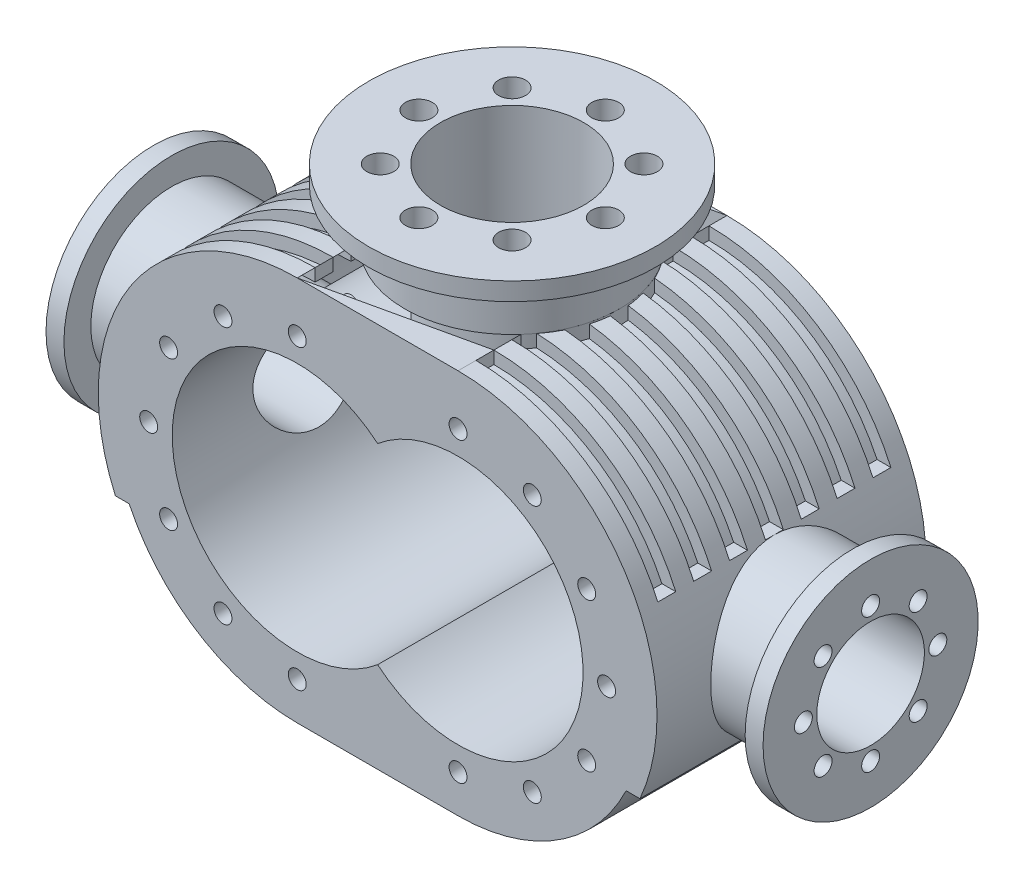
from build123d import *

# Parameters (mm, degrees)
Y_KSEKLIK_EKSTR_ZYON1_DEPTH = 75
Y_KSEKLIK_EKSTR_ZYON2_DEPTH = 75
IZIM1_10_W                  = 89.69
IZIM1_10_H                  = 7
Y_KSEKLIK_EKSTR_ZYON3_DEPTH = 75
IZIM3_W                     = 89.69
IZIM3_H                     = 7
KES_EKSTR_ZYON4_DEPTH       = 5.991017223
KES_EKSTR_ZYON4_DEPTH_BACK  = 155.991017223
Y_KSEKLIK_EKSTR_ZYON4_START = -8.110127
IZIM4_R                     = 60
Y_KSEKLIK_EKSTR_ZYON4_DEPTH = 8.110127
IZIM5_R                     = 40
KES_EKSTR_ZYON5_DEPTH       = 112
IZIM6_R                     = 30
KES_EKSTR_ZYON6_DEPTH       = 401
IZIM7_R                     = 5
KES_EKSTR_ZYON7_DEPTH       = 30
IZIM8_R                     = 5
KES_EKSTR_ZYON8_DEPTH       = 30
IZIM9_R                     = 7.5
KES_EKSTR_ZYON9_DEPTH       = 40
Y_KSEKLIK_EKSTR_ZYON5_DEPTH = 10
L_O_ALTMA2_COUNT            = 10
L_O_ALTMA2_PITCH            = 20
AYNALAMA3_COPY_1_DEPTH      = 10
AYNALAMA3_COPY_2_DEPTH      = 10
AYNALAMA3_COPY_3_DEPTH      = 10
AYNALAMA3_COPY_4_DEPTH      = 10
AYNALAMA3_COPY_5_DEPTH      = 10
AYNALAMA3_COPY_6_DEPTH      = 10
AYNALAMA3_COPY_7_DEPTH      = 10


with BuildPart() as part:
    # Çizim1 → Yükseklik-Ekstrüzyon1 (new body, symmetric)
    with BuildSketch(Plane.XY):
        with BuildLine():
            Line((-44.845, 111), (-44.845, 104))
            ThreePointArc((-44.845, 104), (-148.845, 0), (-44.845, -104))
            Line((-44.845, -104), (-44.845, -111))
            ThreePointArc((-44.845, -111), (-155.845, 0), (-44.845, 111))
        make_face()
    extrude(amount=Y_KSEKLIK_EKSTR_ZYON1_DEPTH, both=True)

    # Çizim1<5> → Döndür2 (revolve)
    with BuildSketch(Plane.XY):
        with BuildLine():
            Line((-200, 0), (-155.845, 0))
            ThreePointArc((-155.845, 0), (-153.436164451, 22.999108745), (-146.314207152, 45))
            Line((-146.314207152, 45), (-190, 45))
            Line((-190, 45), (-190, 60))
            Line((-190, 60), (-200, 60))
            Line((-200, 60), (-200, 0))
        make_face()
    revolve(axis=Axis((0, 0, 0), (1, 0, 0)))



with BuildPart() as body_2:
    # Çizim1<6> → Döndür3 (revolve)
    with BuildSketch(Plane.XY):
        with BuildLine():
            Line((200, 0), (200, 60))
            Line((200, 60), (190, 60))
            Line((190, 60), (190, 45))
            Line((190, 45), (146.314207152, 45))
            ThreePointArc((146.314207152, 45), (153.436164451, 22.999108745), (155.845, 0))
            Line((155.845, 0), (200, 0))
        make_face()
    revolve(axis=Axis((0, 0, 0), (1, 0, 0)))


with BuildPart() as body_3:
    # Çizim1<7> → Döndür4 (revolve)
    with BuildSketch(Plane.XY):
        with BuildLine():
            Line((-44.845, 111), (0, 111))
            Line((0, 111), (0, 151.000138756))
            Line((0, 151.000138756), (-79.991017223, 151.000138756))
            Line((-79.991017223, 151.000138756), (-79.991017223, 141.000138756))
            Line((-79.991017223, 141.000138756), (-59.991017223, 141.000138756))
            Line((-59.991017223, 141.000138756), (-59.991017223, 109.961803197))
            ThreePointArc((-59.991017223, 109.961803197), (-52.435778786, 110.740146638), (-44.845, 111))
        make_face()
    revolve(axis=Axis((0, 159.5984811, 0), (0, -1, 0)))


with BuildPart() as part_1:
    add(part.part)

    add(body_2.part)  # Yükseklik-Ekstrüzyon2 merges body 2

    add(body_3.part)  # Yükseklik-Ekstrüzyon2 merges body 3
    # Çizim1<9> → Yükseklik-Ekstrüzyon2 (add, symmetric)
    with BuildSketch(Plane.XY):
        with BuildLine():
            Line((-44.845, -104), (44.845, -104))
            ThreePointArc((44.845, -104), (148.845, 0), (44.845, 104))
            Line((44.845, 104), (44.845, 111))
            Line((44.845, 111), (-44.845, 111))
            Line((-44.845, 111), (-44.845, 104))
            ThreePointArc((-44.845, 104), (-148.845, 0), (-44.845, -104))
        make_face()
        with BuildLine():
            ThreePointArc((0, -53.422733691), (114.595, 0), (0, 53.422733691))
            ThreePointArc((0, 53.422733691), (-114.595, 0), (0, -53.422733691))
        make_face(mode=Mode.SUBTRACT)
    extrude(amount=Y_KSEKLIK_EKSTR_ZYON2_DEPTH, both=True)

    # Çizim1<10> → Yükseklik-Ekstrüzyon3 (add, symmetric)
    with BuildSketch(Plane.XY):
        with BuildLine():
            ThreePointArc((44.845, -104), (148.845, 0), (44.845, 104))
            Line((44.845, 104), (44.845, 111))
            ThreePointArc((44.845, 111), (155.845, 0), (44.845, -111))
            Line((44.845, -111), (44.845, -104))
        make_face()
        with Locations((0, -107.5)):
            Rectangle(IZIM1_10_W, IZIM1_10_H)
    extrude(amount=Y_KSEKLIK_EKSTR_ZYON3_DEPTH, both=True)

    # Çizim3 → Kes-Ekstrüzyon4 (cut, two sides)
    with BuildSketch(Plane.XY.offset(75)) as kes_ekstr_zyon4_sk:
        with BuildLine():
            ThreePointArc((-44.845, 111), (-105.367723005, 93.048374516), (-146.314207152, 45))
            Line((-146.314207152, 45), (-138.605332764, 45))
            ThreePointArc((-138.605332764, 45), (-100.234529697, 88.022724339), (-44.845, 104))
            Line((-44.845, 104), (-44.845, 111))
        make_face()
        with BuildLine():
            Line((-138.605332764, -45), (-146.314207152, -45))
            ThreePointArc((-146.314207152, -45), (-105.367723005, -93.048374516), (-44.845, -111))
            Line((-44.845, -111), (-44.845, -104))
            ThreePointArc((-44.845, -104), (-100.234529697, -88.022724339), (-138.605332764, -45))
        make_face()
        with Locations((0, -107.5)):
            Rectangle(IZIM3_W, IZIM3_H)
        with BuildLine():
            Line((44.845, -104), (44.845, -111))
            ThreePointArc((44.845, -111), (105.367723005, -93.048374516), (146.314207152, -45))
            Line((146.314207152, -45), (138.605332764, -45))
            ThreePointArc((138.605332764, -45), (100.234529697, -88.022724339), (44.845, -104))
        make_face()
        with BuildLine():
            Line((138.605332764, 45), (146.314207152, 45))
            ThreePointArc((146.314207152, 45), (105.367723005, 93.048374516), (44.845, 111))
            Line((44.845, 111), (44.845, 104))
            ThreePointArc((44.845, 104), (100.234529697, 88.022724339), (138.605332764, 45))
        make_face()
    extrude(amount=KES_EKSTR_ZYON4_DEPTH, mode=Mode.SUBTRACT)
    extrude(kes_ekstr_zyon4_sk.sketch, amount=-KES_EKSTR_ZYON4_DEPTH_BACK, mode=Mode.SUBTRACT)

    # Çizim4 → Yükseklik-Ekstrüzyon4 (add)
    with BuildSketch(Plane(origin=(0, 111, 0), x_dir=(1, 0, 0), z_dir=(0, 1, 0)).offset(Y_KSEKLIK_EKSTR_ZYON4_START)):
        Circle(IZIM4_R)
    extrude(amount=Y_KSEKLIK_EKSTR_ZYON4_DEPTH)

    # Çizim5 → Kes-Ekstrüzyon5 (cut)
    with BuildSketch(Plane(origin=(0, 151.000138756, 0), x_dir=(1, 0, 0), z_dir=(0, 1, 0))):
        Circle(IZIM5_R)
    extrude(amount=-KES_EKSTR_ZYON5_DEPTH, mode=Mode.SUBTRACT)

    # Çizim6 → Kes-Ekstrüzyon6 (cut, through all)
    with BuildSketch(Plane.ZY.offset(200)):
        Circle(IZIM6_R)
    extrude(amount=-KES_EKSTR_ZYON6_DEPTH, mode=Mode.SUBTRACT)

    # Çizim7 → Kes-Ekstrüzyon7 (cut)
    with BuildSketch(Plane(origin=(0, 0, -75), x_dir=(-1, 0, 0), z_dir=(0, 0, -1))):
        with Locations((-127.72, 0)):
            Circle(IZIM7_R)
        with Locations((-116.616855339, -41.4375)):
            Circle(IZIM7_R)
        with Locations((-86.2825, -71.771855339)):
            Circle(IZIM7_R)
        with Locations((-44.845, -82.875)):
            Circle(IZIM7_R)
        with Locations((-116.616855339, 41.4375)):
            Circle(IZIM7_R)
        with Locations((-86.2825, 71.771855339)):
            Circle(IZIM7_R)
        with Locations((-44.845, 82.875)):
            Circle(IZIM7_R)
        with Locations((44.845, -82.875)):
            Circle(IZIM7_R)
        with Locations((86.2825, -71.771855339)):
            Circle(IZIM7_R)
        with Locations((116.616855339, -41.4375)):
            Circle(IZIM7_R)
        with Locations((127.72, 0)):
            Circle(IZIM7_R)
        with Locations((116.616855339, 41.4375)):
            Circle(IZIM7_R)
        with Locations((86.2825, 71.771855339)):
            Circle(IZIM7_R)
        with Locations((44.845, 82.875)):
            Circle(IZIM7_R)
    kes_ekstr_zyon7 = extrude(amount=-KES_EKSTR_ZYON7_DEPTH, mode=Mode.SUBTRACT)

    # Aynalama1: Kes-Ekstrüzyon7 across plane
    add(kes_ekstr_zyon7.mirror(Plane.XY), mode=Mode.SUBTRACT)

    # Çizim8 → Kes-Ekstrüzyon8 (cut)
    with BuildSketch(Plane.ZY.offset(200)):
        with Locations((0, 37.5)):
            Circle(IZIM8_R)
        with Locations((26.516504294, 26.516504294)):
            Circle(IZIM8_R)
        with Locations((37.5, 0)):
            Circle(IZIM8_R)
        with Locations((26.516504294, -26.516504294)):
            Circle(IZIM8_R)
        with Locations((0, -37.5)):
            Circle(IZIM8_R)
        with Locations((-26.516504294, -26.516504294)):
            Circle(IZIM8_R)
        with Locations((-37.5, 0)):
            Circle(IZIM8_R)
        with Locations((-26.516504294, 26.516504294)):
            Circle(IZIM8_R)
    kes_ekstr_zyon8 = extrude(amount=-KES_EKSTR_ZYON8_DEPTH, mode=Mode.SUBTRACT)

    # Aynalama2: Kes-Ekstrüzyon8 across plane
    add(kes_ekstr_zyon8.mirror(Plane(origin=(0, 0, 0), x_dir=(0, 0, 1), z_dir=(1, 0, 0))), mode=Mode.SUBTRACT)

    # Çizim9 → Kes-Ekstrüzyon9 (cut)
    with BuildSketch(Plane(origin=(0, 151.000138756, 0), x_dir=(1, 0, 0), z_dir=(0, 1, 0))):
        with Locations((52, 0)):
            Circle(IZIM9_R)
        with Locations((36.769552622, -36.769552622)):
            Circle(IZIM9_R)
        with Locations((0, -52)):
            Circle(IZIM9_R)
        with Locations((-36.769552622, -36.769552622)):
            Circle(IZIM9_R)
        with Locations((-52, 0)):
            Circle(IZIM9_R)
        with Locations((-36.769552622, 36.769552622)):
            Circle(IZIM9_R)
        with Locations((0, 52)):
            Circle(IZIM9_R)
        with Locations((36.769552622, 36.769552622)):
            Circle(IZIM9_R)
    extrude(amount=-KES_EKSTR_ZYON9_DEPTH, mode=Mode.SUBTRACT)

    # Çizim10 → Yükseklik-Ekstrüzyon5 (add)
    with BuildSketch(Plane.XY.offset(-75)):
        with BuildLine():
            ThreePointArc((-44.845, 111), (-105.367723005, 93.048374516), (-146.314207152, 45))
            Line((-146.314207152, 45), (-138.605332764, 45))
            ThreePointArc((-138.605332764, 45), (-100.234529697, 88.022724339), (-44.845, 104))
            Line((-44.845, 104), (-44.845, 111))
        make_face()
    y_kseklik_ekstr_zyon5 = extrude(amount=Y_KSEKLIK_EKSTR_ZYON5_DEPTH)

    # LÇoğaltma2: Yükseklik-Ekstrüzyon5 ×10, 2 skipped
    with Locations(*[(0, 0, i * L_O_ALTMA2_PITCH) for i in range(1, L_O_ALTMA2_COUNT) if i not in (8, 9)]):
        add(y_kseklik_ekstr_zyon5)

    # Aynalama3: Yükseklik-Ekstrüzyon5 across plane
    add(y_kseklik_ekstr_zyon5.mirror(Plane(origin=(0, 0, 0), x_dir=(0, 0, 1), z_dir=(1, 0, 0))))

    # Aynalama3 copy 1 sketch → Aynalama3 copy 1 (add)
    with BuildSketch(Plane(origin=(0, 0, -55), x_dir=(-1, 0, 0), z_dir=(0, 0, 1))):
        with BuildLine():
            ThreePointArc((-44.845, -111), (-105.367723005, -93.048374516), (-146.314207152, -45))
            Line((-146.314207152, -45), (-138.605332764, -45))
            ThreePointArc((-138.605332764, -45), (-100.234529697, -88.022724339), (-44.845, -104))
            Line((-44.845, -104), (-44.845, -111))
        make_face()
    extrude(amount=AYNALAMA3_COPY_1_DEPTH)

    # Aynalama3 copy 2 sketch → Aynalama3 copy 2 (add)
    with BuildSketch(Plane(origin=(0, 0, -35), x_dir=(-1, 0, 0), z_dir=(0, 0, 1))):
        with BuildLine():
            ThreePointArc((-44.845, -111), (-105.367723005, -93.048374516), (-146.314207152, -45))
            Line((-146.314207152, -45), (-138.605332764, -45))
            ThreePointArc((-138.605332764, -45), (-100.234529697, -88.022724339), (-44.845, -104))
            Line((-44.845, -104), (-44.845, -111))
        make_face()
    extrude(amount=AYNALAMA3_COPY_2_DEPTH)

    # Aynalama3 copy 3 sketch → Aynalama3 copy 3 (add)
    with BuildSketch(Plane(origin=(0, 0, -15), x_dir=(-1, 0, 0), z_dir=(0, 0, 1))):
        with BuildLine():
            ThreePointArc((-44.845, -111), (-105.367723005, -93.048374516), (-146.314207152, -45))
            Line((-146.314207152, -45), (-138.605332764, -45))
            ThreePointArc((-138.605332764, -45), (-100.234529697, -88.022724339), (-44.845, -104))
            Line((-44.845, -104), (-44.845, -111))
        make_face()
    extrude(amount=AYNALAMA3_COPY_3_DEPTH)

    # Aynalama3 copy 4 sketch → Aynalama3 copy 4 (add)
    with BuildSketch(Plane(origin=(0, 0, 5), x_dir=(-1, 0, 0), z_dir=(0, 0, 1))):
        with BuildLine():
            ThreePointArc((-44.845, -111), (-105.367723005, -93.048374516), (-146.314207152, -45))
            Line((-146.314207152, -45), (-138.605332764, -45))
            ThreePointArc((-138.605332764, -45), (-100.234529697, -88.022724339), (-44.845, -104))
            Line((-44.845, -104), (-44.845, -111))
        make_face()
    extrude(amount=AYNALAMA3_COPY_4_DEPTH)

    # Aynalama3 copy 5 sketch → Aynalama3 copy 5 (add)
    with BuildSketch(Plane(origin=(0, 0, 25), x_dir=(-1, 0, 0), z_dir=(0, 0, 1))):
        with BuildLine():
            ThreePointArc((-44.845, -111), (-105.367723005, -93.048374516), (-146.314207152, -45))
            Line((-146.314207152, -45), (-138.605332764, -45))
            ThreePointArc((-138.605332764, -45), (-100.234529697, -88.022724339), (-44.845, -104))
            Line((-44.845, -104), (-44.845, -111))
        make_face()
    extrude(amount=AYNALAMA3_COPY_5_DEPTH)

    # Aynalama3 copy 6 sketch → Aynalama3 copy 6 (add)
    with BuildSketch(Plane(origin=(0, 0, 45), x_dir=(-1, 0, 0), z_dir=(0, 0, 1))):
        with BuildLine():
            ThreePointArc((-44.845, -111), (-105.367723005, -93.048374516), (-146.314207152, -45))
            Line((-146.314207152, -45), (-138.605332764, -45))
            ThreePointArc((-138.605332764, -45), (-100.234529697, -88.022724339), (-44.845, -104))
            Line((-44.845, -104), (-44.845, -111))
        make_face()
    extrude(amount=AYNALAMA3_COPY_6_DEPTH)

    # Aynalama3 copy 7 sketch → Aynalama3 copy 7 (add)
    with BuildSketch(Plane(origin=(0, 0, 65), x_dir=(-1, 0, 0), z_dir=(0, 0, 1))):
        with BuildLine():
            ThreePointArc((-44.845, -111), (-105.367723005, -93.048374516), (-146.314207152, -45))
            Line((-146.314207152, -45), (-138.605332764, -45))
            ThreePointArc((-138.605332764, -45), (-100.234529697, -88.022724339), (-44.845, -104))
            Line((-44.845, -104), (-44.845, -111))
        make_face()
    extrude(amount=AYNALAMA3_COPY_7_DEPTH)


solid = part_1.part
